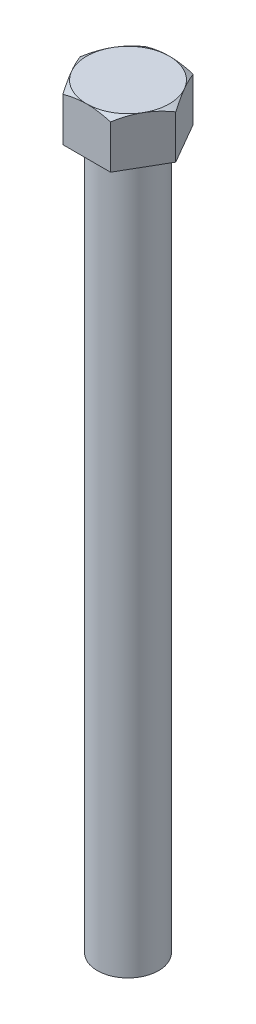
from build123d import *

# Parameters (mm, degrees)
BOSS_EXTRUDE1_DEPTH = 20
SKETCH2_OUTSIDE_W   = 123.112
SKETCH2_OUTSIDE_H   = 117.698
SKETCH2_OUTSIDE_R   = 17.5
CUT_EXTRUDE1_DEPTH  = 20
CUT_EXTRUDE1_TAPER  = 60
SKETCH3_R           = 13
BOSS_EXTRUDE2_DEPTH = 300


with BuildPart() as part:
    # Sketch1 → Boss-Extrude1 (new body)
    with BuildSketch(Plane(origin=(0, 0, 0), x_dir=(1, 0, 0), z_dir=(0, 1, 0))):
        Polygon((-10.103629711, -17.5), (10.103629711, -17.5), (20.207259422, 0), (10.103629711, 17.5), (-10.103629711, 17.5), (-20.207259422, 0), align=None)
    extrude(amount=BOSS_EXTRUDE1_DEPTH)

    # Sketch2 outside → Cut-Extrude1 (cut)
    with BuildSketch(Plane(origin=(0, 20, 0), x_dir=(1, 0, 0), z_dir=(0, 1, 0))):
        Rectangle(SKETCH2_OUTSIDE_W, SKETCH2_OUTSIDE_H)
        Circle(SKETCH2_OUTSIDE_R, mode=Mode.SUBTRACT)
    extrude(amount=-CUT_EXTRUDE1_DEPTH, taper=CUT_EXTRUDE1_TAPER, mode=Mode.SUBTRACT)

    # Sketch3 → Boss-Extrude2 (add)
    with BuildSketch(Plane.XZ):
        Circle(SKETCH3_R)
    extrude(amount=BOSS_EXTRUDE2_DEPTH)


solid = part.part
